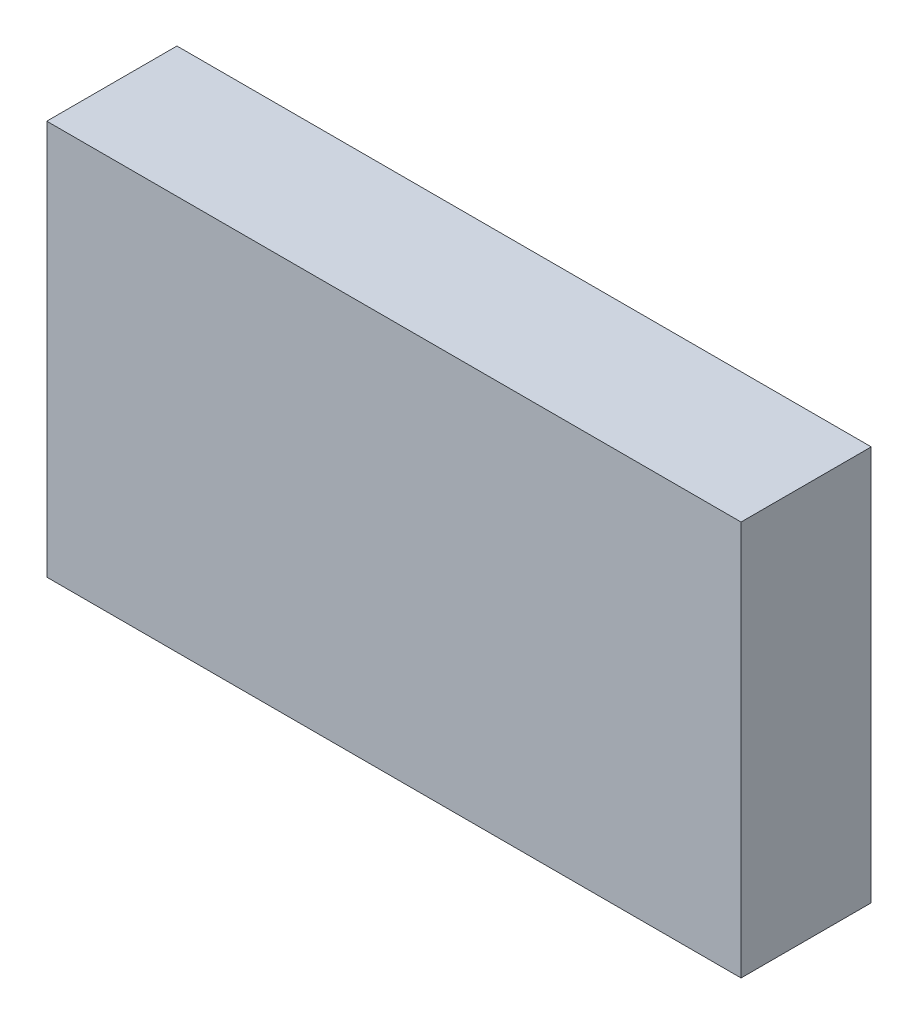
from build123d import *

# Parameters (mm, degrees)
SKETCH1_W           = 160
SKETCH1_H           = 91
BOSS_EXTRUDE1_DEPTH = 30


with BuildPart() as part:
    # Sketch1 → Boss-Extrude1 (new body)
    with BuildSketch(Plane.XY):
        Rectangle(SKETCH1_W, SKETCH1_H)
    extrude(amount=BOSS_EXTRUDE1_DEPTH)


solid = part.part
